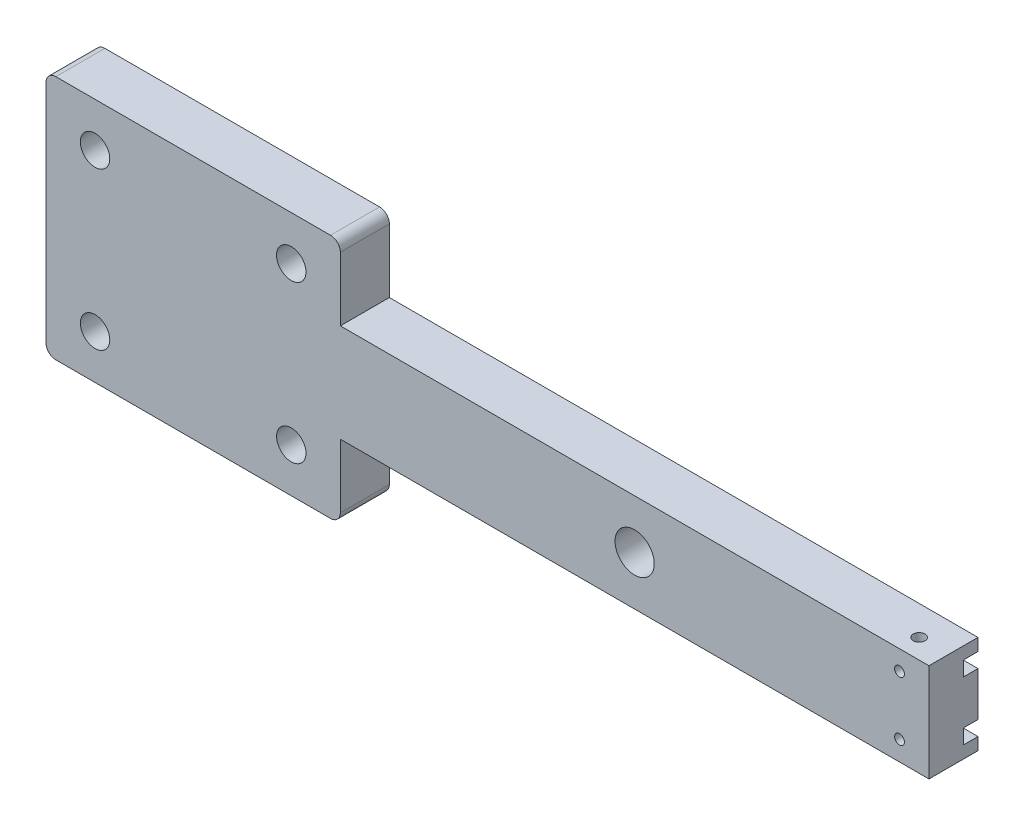
from build123d import *

# Parameters (mm, degrees)
BOSS_EXTRUDE1_DEPTH = 10
SKETCH2_R           = 3
CUT_EXTRUDE1_DEPTH  = 7
SKETCH4_W           = 40
SKETCH4_H           = 40
CUT_EXTRUDE3_DEPTH  = 3
SKETCH5_R           = 1
SKETCH5_R_2         = 4
CUT_EXTRUDE4_DEPTH  = 11
SKETCH6_W           = 3
SKETCH6_H           = 3
CUT_EXTRUDE5_DEPTH  = 130
FILLET1_R           = 2
SKETCH7_R           = 1.2
CUT_EXTRUDE6_DEPTH  = 36


with BuildPart() as part:
    # Sketch1 → Boss-Extrude1 (new body)
    with BuildSketch(Plane.XY):
        Polygon((0, 0), (60, 0), (60, 15), (180, 15), (180, 35), (60, 35), (60, 50), (0, 50), align=None)
    extrude(amount=BOSS_EXTRUDE1_DEPTH)

    # Sketch2 → Cut-Extrude1 (cut)
    with BuildSketch(Plane.XY.offset(10)):
        with Locations((10, 9)):
            Circle(SKETCH2_R)
        with Locations((50, 9)):
            Circle(SKETCH2_R)
        with Locations((50, 41)):
            Circle(SKETCH2_R)
        with Locations((10, 41)):
            Circle(SKETCH2_R)
    extrude(amount=-CUT_EXTRUDE1_DEPTH, mode=Mode.SUBTRACT)

    # Sketch4 → Cut-Extrude3 (cut)
    with BuildSketch(Plane(origin=(0, 0, 0), x_dir=(-1, 0, 0), z_dir=(0, 0, -1))):
        with Locations((-30, 25)):
            Rectangle(SKETCH4_W, SKETCH4_H)
    extrude(amount=-CUT_EXTRUDE3_DEPTH, mode=Mode.SUBTRACT)

    # Sketch5 → Cut-Extrude4 (cut, through all)
    with BuildSketch(Plane(origin=(0, 0, 0), x_dir=(-1, 0, 0), z_dir=(0, 0, -1))):
        with Locations((-174, 31)):
            Circle(SKETCH5_R)
        with Locations((-174, 19)):
            Circle(SKETCH5_R)
        with Locations((-120, 25)):
            Circle(SKETCH5_R_2)
    extrude(amount=-CUT_EXTRUDE4_DEPTH, mode=Mode.SUBTRACT)

    # Sketch6 → Cut-Extrude5 (cut)
    with BuildSketch(Plane(origin=(180, 0, 0), x_dir=(0, 0, -1), z_dir=(1, 0, 0))):
        with Locations((-1.5, 31)):
            Rectangle(SKETCH6_W, SKETCH6_H)
        with Locations((-1.5, 19)):
            Rectangle(SKETCH6_W, SKETCH6_H)
    extrude(amount=-CUT_EXTRUDE5_DEPTH, mode=Mode.SUBTRACT)

    # Fillet1
    fillet1_edges = [part.edges().sort_by_distance(p)[0] for p in [
        (0, 50, 5),
        (60, 50, 5),
        (60, 0, 5),
        (0, 0, 5),
    ]]
    fillet(fillet1_edges, radius=FILLET1_R)

    # Sketch7 → Cut-Extrude6 (cut, through all)
    with BuildSketch(Plane(origin=(0, 35, 0), x_dir=(1, 0, 0), z_dir=(0, 1, 0))):
        with Locations((174, -6)):
            Circle(SKETCH7_R)
    extrude(amount=-CUT_EXTRUDE6_DEPTH, mode=Mode.SUBTRACT)


solid = part.part
